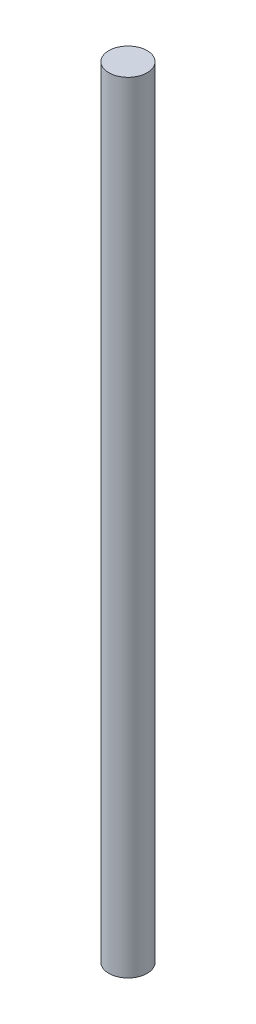
from build123d import *

# Parameters (mm, degrees)
SKETCH1_R           = 1.5
BOSS_EXTRUDE1_DEPTH = 61


with BuildPart() as part:
    # Sketch1 → Boss-Extrude1 (new body)
    with BuildSketch(Plane(origin=(0, 0, 0), x_dir=(1, 0, 0), z_dir=(0, 1, 0))):
        Circle(SKETCH1_R)
    extrude(amount=BOSS_EXTRUDE1_DEPTH)


solid = part.part
